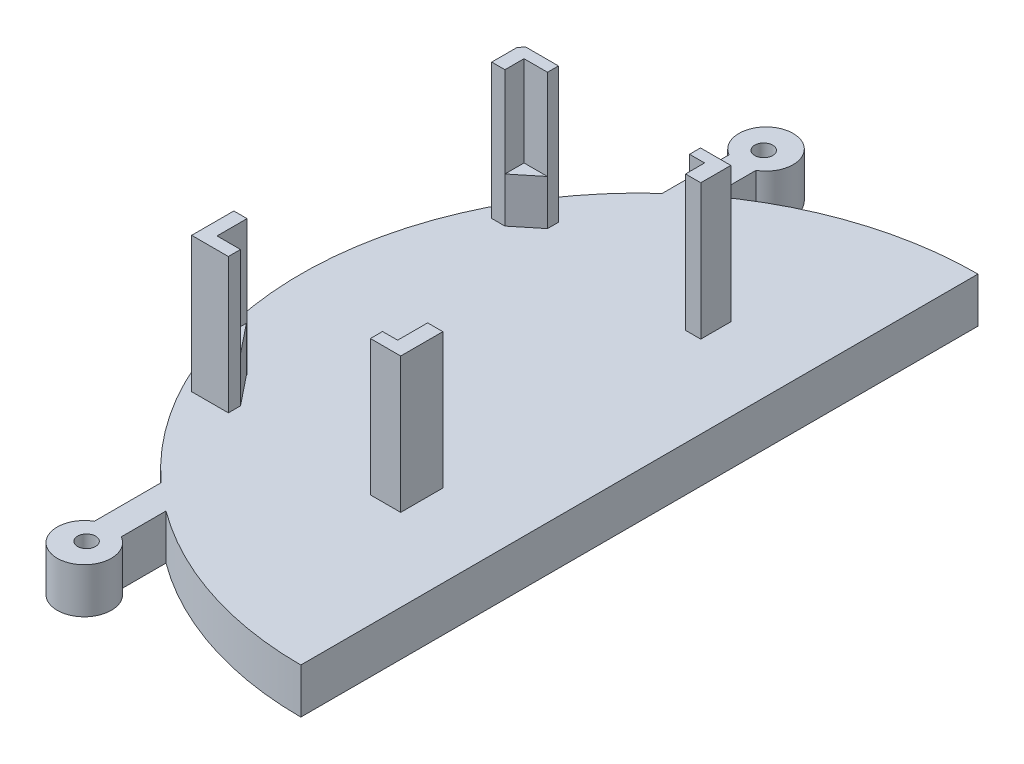
from build123d import *

# Parameters (mm, degrees)
AUFSATZ_LINEAR_AUSTRAGEN1_DEPTH = 5
AUFSATZ_LINEAR_AUSTRAGEN2_DEPTH = 5
SKIZZE5_R                       = 3
AUFSATZ_LINEAR_AUSTRAGEN3_DEPTH = 5
SKIZZE6_R                       = 1
SCHNITT_LINEAR_AUSTRAGEN3_DEPTH = 5
AUFSATZ_LINEAR_AUSTRAGEN4_DEPTH = 15
SKIZZE8_W                       = 20
SKIZZE8_H                       = 34
SCHNITT_LINEAR_AUSTRAGEN4_DEPTH = 15
SKIZZE9_W                       = 15.731932776
SKIZZE9_H                       = 1.345677625
SKIZZE9_W_2                     = 1.464910579
SKIZZE9_H_2                     = 28.562069045
SKIZZE9_H_3                     = 1.21563576
SKIZZE9_W_3                     = 1.686857954
SCHNITT_LINEAR_AUSTRAGEN5_DEPTH = 15
AUFSATZ_LINEAR_AUSTRAGEN5_DEPTH = 5


with BuildPart() as part:
    # Skizze1 → Aufsatz-Linear austragen1 (new body)
    with BuildSketch(Plane(origin=(0, 0, 0), x_dir=(1, 0, 0), z_dir=(0, 1, 0))):
        with BuildLine():
            Line((0, 0), (0, -75))
            ThreePointArc((0, -75), (-37.5, -37.5), (0, 0))
        make_face()
    extrude(amount=AUFSATZ_LINEAR_AUSTRAGEN1_DEPTH)

    # Skizze4 → Aufsatz-Linear austragen2 (add)
    with BuildSketch(Plane(origin=(0, 5, 0), x_dir=(1, 0, 0), z_dir=(0, 1, 0))):
        Polygon((-22.238082181, -7.305336549), (-22.238082181, 0.251909769), (-25.220656299, 0.251909769), (-25.220656299, -9.748090231), (-22.238082181, -9.748090231), align=None)
        Polygon((-22.238082181, -67.694663451), (-22.238082181, -75.251909769), (-25.220656299, -75.251909769), (-25.220656299, -65.251909769), (-22.238082181, -65.251909769), align=None)
    extrude(amount=-AUFSATZ_LINEAR_AUSTRAGEN2_DEPTH)

    # Skizze5 → Aufsatz-Linear austragen3 (add)
    with BuildSketch(Plane(origin=(0, 5, 0), x_dir=(1, 0, 0), z_dir=(0, 1, 0))):
        with Locations((-23.72936924, 0.251909769)):
            Circle(SKIZZE5_R)
        with Locations((-23.72936924, -75.251909769)):
            Circle(SKIZZE5_R)
    extrude(amount=-AUFSATZ_LINEAR_AUSTRAGEN3_DEPTH)

    # Skizze6 → Schnitt-Linear austragen3 (cut)
    with BuildSketch(Plane(origin=(0, 5, 0), x_dir=(1, 0, 0), z_dir=(0, 1, 0))):
        with Locations((-23.72936924, 0)):
            Circle(SKIZZE6_R)
        with Locations((-23.72936924, -75)):
            Circle(SKIZZE6_R)
    extrude(amount=-SCHNITT_LINEAR_AUSTRAGEN3_DEPTH, mode=Mode.SUBTRACT)

    # Skizze7 → Aufsatz-Linear austragen4 (add)
    with BuildSketch(Plane(origin=(0, 5, 0), x_dir=(1, 0, 0), z_dir=(0, 1, 0))):
        Polygon((-32.258719726, -18.830892905), (-32.258719726, -54.830892905), (-9.106951193, -54.830892905), (-9.106951193, -18.26957952), (-31.844703161, -18.26957952), align=None)
    extrude(amount=AUFSATZ_LINEAR_AUSTRAGEN4_DEPTH)

    # Skizze8 → Schnitt-Linear austragen4 (cut)
    with BuildSketch(Plane(origin=(0, 20, 0), x_dir=(1, 0, 0), z_dir=(0, 1, 0))):
        with Locations((-20.793809147, -36.48521528)):
            Rectangle(SKIZZE8_W, SKIZZE8_H)
    extrude(amount=-SCHNITT_LINEAR_AUSTRAGEN4_DEPTH, mode=Mode.SUBTRACT)

    # Skizze9 → Schnitt-Linear austragen5 (cut)
    with BuildSketch(Plane(origin=(0, 20, 0), x_dir=(1, 0, 0), z_dir=(0, 1, 0))):
        with Locations((-20.328643091, -54.158054093)):
            Rectangle(SKIZZE9_W, SKIZZE9_H)
        with Locations((-31.526264436, -35.879751076)):
            Rectangle(SKIZZE9_W_2, SKIZZE9_H_2)
        with Locations((-20.328643091, -18.8773974)):
            Rectangle(SKIZZE9_W, SKIZZE9_H_3)
        with Locations((-9.95038017, -35.879751076)):
            Rectangle(SKIZZE9_W_3, SKIZZE9_H_2)
    extrude(amount=-SCHNITT_LINEAR_AUSTRAGEN5_DEPTH, mode=Mode.SUBTRACT)

    # Skizze10 → Aufsatz-Linear austragen5 (add)
    with BuildSketch(Plane(origin=(0, 5, 0), x_dir=(1, 0, 0), z_dir=(0, 1, 0))):
        Polygon((-28.194609479, -53.48521528), (-30.793809147, -50.234762972), (-30.793809147, -53.48521528), align=None)
        Polygon((-30.793809147, -21.598716553), (-30.793809147, -19.48521528), (-28.194609479, -19.48521528), align=None)
        Polygon((-12.462676703, -19.48521528), (-10.793809147, -19.48521528), (-10.793809147, -21.598716553), align=None)
        Polygon((-12.462676703, -53.48521528), (-10.793809147, -53.48521528), (-10.793809147, -50.234762972), align=None)
    extrude(amount=AUFSATZ_LINEAR_AUSTRAGEN5_DEPTH)


solid = part.part
